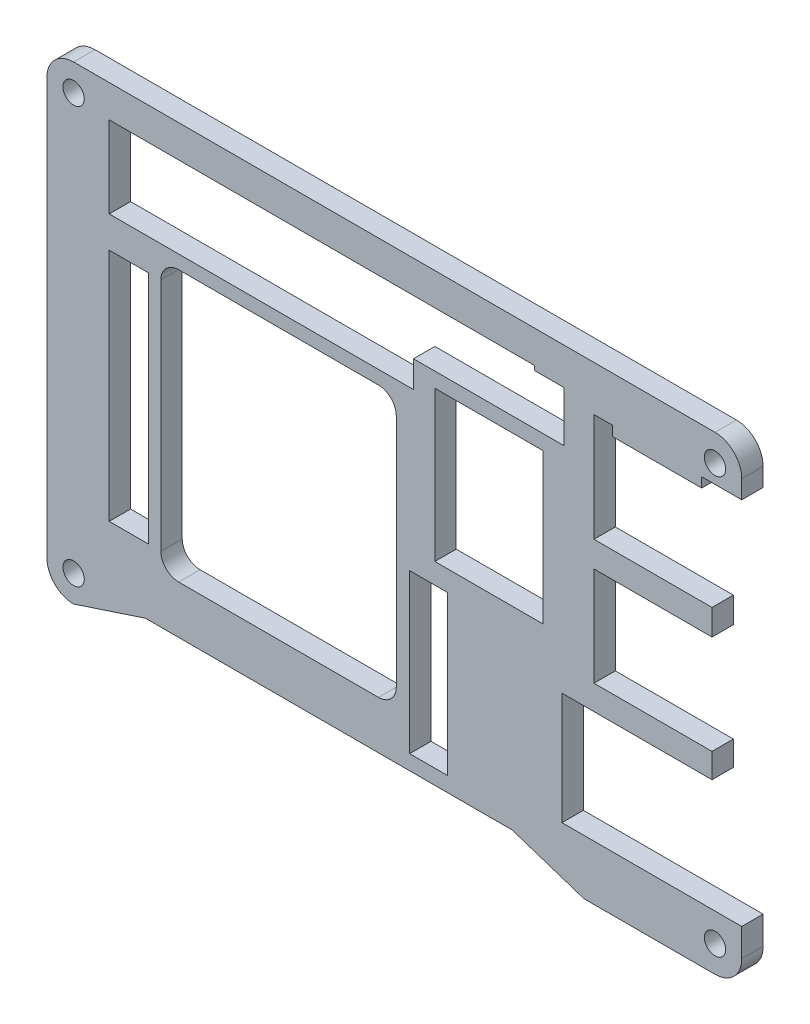
from build123d import *

# Parameters (mm, degrees)
SKETCH1_R           = 1.3462
SKETCH1_W           = 5.4034
SKETCH1_H           = 22.6066
SKETCH1_W_2         = 60.6932
SKETCH1_H_2         = 7.81
SKETCH1_W_3         = 15.431
SKETCH1_H_3         = 21.4039
SKETCH1_W_4         = 31.9679
SKETCH1_H_4         = 18.2371
SKETCH1_W_5         = 5.588
SKETCH1_H_5         = 33.5001
BOSS_EXTRUDE1_DEPTH = 3.048
SKETCH2_W           = 33.5789
SKETCH2_H           = 38.5801
CUT_EXTRUDE1_DEPTH  = 4.048
FILLET1_R           = 2.54
SKETCH3_R           = 1.524
CUT_EXTRUDE2_DEPTH  = 4.048
SKETCH4_W           = 43.3979
SKETCH4_H           = 3.81
CUT_EXTRUDE3_DEPTH  = 4.048
SKETCH5_W           = 12.7
SKETCH5_H           = 1.397
BOSS_EXTRUDE2_DEPTH = 3.048
SKETCH6_W           = 4.1917
SKETCH6_H           = 7.175
CUT_EXTRUDE4_DEPTH  = 4.048


with BuildPart() as part:
    # Sketch1 → Boss-Extrude1 (new body)
    with BuildSketch(Plane.XY):
        with BuildLine():
            Line((61.214907375, 24.068294304), (40.134807375, 24.068294304))
            Line((40.134807375, 24.068294304), (40.134807375, 8.658194304))
            Line((40.134807375, 8.658194304), (56.975007375, 8.658194304))
            Line((56.975007375, 8.658194304), (56.975007375, 4.997894304))
            Line((56.975007375, 4.997894304), (40.134807375, 4.997894304))
            Line((40.134807375, 4.997894304), (40.134807375, -9.121805696))
            Line((40.134807375, -9.121805696), (56.975007375, -9.121805696))
            Line((56.975007375, -9.121805696), (56.975007375, -12.628005696))
            Line((56.975007375, -12.628005696), (35.575007375, -12.628005696))
            Line((35.575007375, -12.628005696), (35.575007375, -28.627805696))
            Line((35.575007375, -28.627805696), (61.214907375, -28.627805696))
            Line((61.214907375, -28.627805696), (61.214907375, -32.613401529))
            ThreePointArc((61.214907375, -32.613401529), (60.108826144, -35.325305244), (57.405007375, -36.451005696))
            Line((57.405007375, -36.451005696), (38.714307375, -36.451005696))
            Line((38.714307375, -36.451005696), (28.474307375, -33.084405696))
            Line((28.474307375, -33.084405696), (-23.844892625, -33.084405696))
            Line((-23.844892625, -33.084405696), (-34.084892625, -36.451005696))
            ThreePointArc((-34.084892625, -36.451005696), (-36.778969461, -35.335082532), (-37.894892625, -32.641005696))
            Line((-37.894892625, -32.641005696), (-37.894892625, 26.697694304))
            ThreePointArc((-37.894892625, 26.697694304), (-36.778969461, 29.391771141), (-34.084892625, 30.507694304))
            Line((-34.084892625, 30.507694304), (57.404932375, 30.507694304))
            ThreePointArc((57.404932375, 30.507694304), (60.103884597, 29.386886916), (61.214907375, 26.683892153))
            Line((61.214907375, 26.683892153), (61.214907375, 24.068294304))
        make_face()
        with Locations((57.404932375, 26.697694304)):
            Circle(SKETCH1_R, mode=Mode.SUBTRACT)
        with Locations((57.405007375, -32.641005696)):
            Circle(SKETCH1_R, mode=Mode.SUBTRACT)
        with Locations((-34.084892625, -32.641005696)):
            Circle(SKETCH1_R, mode=Mode.SUBTRACT)
        with Locations((-34.084892625, 26.697694304)):
            Circle(SKETCH1_R, mode=Mode.SUBTRACT)
        with Locations((16.546707375, -19.663505696)):
            Rectangle(SKETCH1_W, SKETCH1_H, mode=Mode.SUBTRACT)
        with Locations((1.341707375, 21.991994304)):
            Rectangle(SKETCH1_W_2, SKETCH1_H_2, mode=Mode.SUBTRACT)
        with Locations((25.156507375, 5.270444304)):
            Rectangle(SKETCH1_W_3, SKETCH1_H_3, mode=Mode.SUBTRACT)
        with Locations((-5.654942625, 1.475544304)):
            Rectangle(SKETCH1_W_4, SKETCH1_H_4, mode=Mode.SUBTRACT)
        with Locations((-26.210892625, -6.948855696)):
            Rectangle(SKETCH1_W_5, SKETCH1_H_5, mode=Mode.SUBTRACT)
    extrude(amount=BOSS_EXTRUDE1_DEPTH)

    # Sketch2 → Cut-Extrude1 (cut, through all)
    with BuildSketch(Plane.XY.offset(3.048)):
        with Locations((-4.849442625, -6.948855696)):
            Rectangle(SKETCH2_W, SKETCH2_H)
    extrude(amount=-CUT_EXTRUDE1_DEPTH, mode=Mode.SUBTRACT)

    # Fillet1
    fillet1_edges = [part.edges().sort_by_distance(p)[0] for p in [
        (-21.638892625, -26.238905696, 1.524),
        (11.940007375, 12.341194304, 1.524),
        (11.940007375, -26.238905696, 1.524),
        (-21.638892625, 12.341194304, 1.524),
    ]]
    fillet(fillet1_edges, radius=FILLET1_R)

    # Sketch3 → Cut-Extrude2 (cut, through all)
    with BuildSketch(Plane.XY.offset(3.048)):
        with Locations((-34.084892625, 26.697694304)):
            Circle(SKETCH3_R)
        with Locations((57.404932375, 26.697694304)):
            Circle(SKETCH3_R)
        with Locations((57.405007375, -32.641005696)):
            Circle(SKETCH3_R)
        with Locations((-34.084892625, -32.641005696)):
            Circle(SKETCH3_R)
    extrude(amount=-CUT_EXTRUDE2_DEPTH, mode=Mode.SUBTRACT)

    # Sketch4 → Cut-Extrude3 (cut, through all)
    with BuildSketch(Plane.XY.offset(3.048)):
        with Locations((-7.305942625, 16.181994304)):
            Rectangle(SKETCH4_W, SKETCH4_H)
    extrude(amount=-CUT_EXTRUDE3_DEPTH, mode=Mode.SUBTRACT)

    # Sketch5 → Boss-Extrude2 (add)
    with BuildSketch(Plane.XY.offset(3.048)):
        with Locations((49.149907375, 23.369794304)):
            Rectangle(SKETCH5_W, SKETCH5_H)
    extrude(amount=-BOSS_EXTRUDE2_DEPTH)

    # Sketch6 → Cut-Extrude4 (cut, through all)
    with BuildSketch(Plane.XY.offset(3.048)):
        with Locations((33.784157375, 21.674494304)):
            Rectangle(SKETCH6_W, SKETCH6_H)
    extrude(amount=-CUT_EXTRUDE4_DEPTH, mode=Mode.SUBTRACT)


solid = part.part
